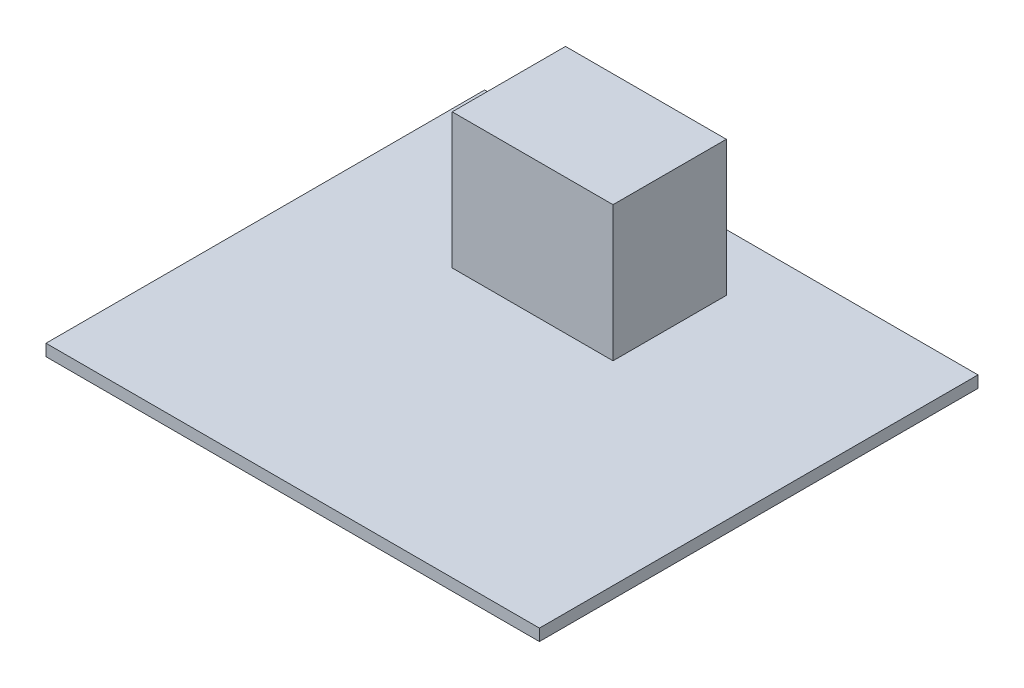
from build123d import *

# Parameters (mm, degrees)
SKETCH1_W           = 67.5
SKETCH1_H           = 60
BOSS_EXTRUDE1_DEPTH = 1.6
SKETCH2_W           = 22
SKETCH2_H           = 15.5
BOSS_EXTRUDE2_DEPTH = 18.5


with BuildPart() as part:
    # Sketch1 → Boss-Extrude1 (new body)
    with BuildSketch(Plane(origin=(0, 0, 0), x_dir=(1, 0, 0), z_dir=(0, 1, 0))):
        Rectangle(SKETCH1_W, SKETCH1_H)
    extrude(amount=BOSS_EXTRUDE1_DEPTH)

    # Sketch2 → Boss-Extrude2 (add)
    with BuildSketch(Plane(origin=(0, 1.6, 0), x_dir=(1, 0, 0), z_dir=(0, 1, 0))):
        with Locations((-3.88, 14.45)):
            Rectangle(SKETCH2_W, SKETCH2_H)
    extrude(amount=BOSS_EXTRUDE2_DEPTH)


solid = part.part
